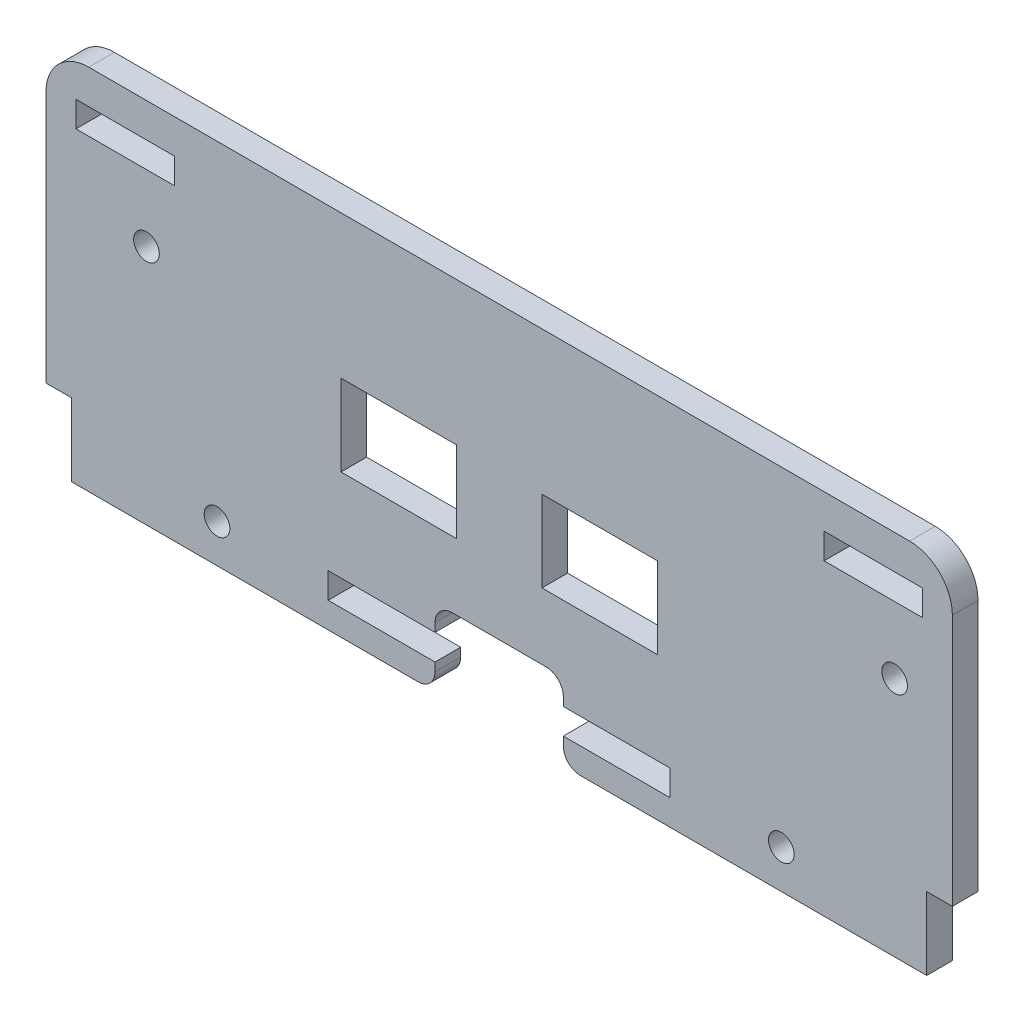
from build123d import *

# Parameters (mm, degrees)
ESBO_O1_W                 = 100
ESBO_O1_H                 = 43
RESSALTO_EXTRUS_O1_DEPTH  = 1.5
ESBO_O2_R                 = 1.5
CORTE_EXTRUS_O1_DEPTH     = 4
SKETCH7_W                 = 13.5
SKETCH7_H                 = 9.5
CUT_EXTRUDE6_DEPTH        = 2.5
CUT_EXTRUDE6_DEPTH_BACK   = 2.5
SKETCH8_W                 = 3
SKETCH8_H                 = 34.5
BOSS_EXTRUDE1_DEPTH       = 1.5
FILLET3_R                 = 2
FILLET4_R                 = 5
SKETCH9_R                 = 1.5
SKETCH9_W                 = 11.5
SKETCH9_H                 = 3
CORTE_GY_53LDK_DEPTH      = 2.5
CORTE_GY_53LDK_DEPTH_BACK = 2.5


with BuildPart() as part:
    # Esboço1 → Ressalto-extrusão1 (new body, symmetric)
    with BuildSketch(Plane.XY):
        Rectangle(ESBO_O1_W, ESBO_O1_H)
    extrude(amount=RESSALTO_EXTRUS_O1_DEPTH, both=True)

    # Esboço2 → Corte-extrusão1 (cut, through all)
    with BuildSketch(Plane.XY.offset(1.5)):
        with Locations((-33, -17)):
            Circle(ESBO_O2_R)
        with Locations((33, -17)):
            Circle(ESBO_O2_R)
        Polygon((-20, -15.5), (-7.5, -15.5), (-7.5, -12.5), (7.5, -12.5), (7.5, -15.5), (20, -15.5), (20, -18.5), (7.5, -18.5), (7.5, -21.5), (-7.5, -21.5), (-7.5, -18.5), (-20, -18.5), align=None)
    extrude(amount=-CORTE_EXTRUS_O1_DEPTH, mode=Mode.SUBTRACT)

    # Sketch7 → Cut-Extrude6 (cut, two sides)
    with BuildSketch(Plane.XY) as cut_extrude6_sk:
        with Locations((-11.75, 0)):
            Rectangle(SKETCH7_W, SKETCH7_H)
        with Locations((11.75, 0)):
            Rectangle(SKETCH7_W, SKETCH7_H)
    extrude(amount=CUT_EXTRUDE6_DEPTH, mode=Mode.SUBTRACT)
    extrude(cut_extrude6_sk.sketch, amount=-CUT_EXTRUDE6_DEPTH_BACK, mode=Mode.SUBTRACT)

    # Sketch8 → Boss-Extrude1 (add, symmetric)
    with BuildSketch(Plane.XY):
        with Locations((-51.5, 4.25)):
            Rectangle(SKETCH8_W, SKETCH8_H)
        with Locations((51.5, 4.25)):
            Rectangle(SKETCH8_W, SKETCH8_H)
    extrude(amount=BOSS_EXTRUDE1_DEPTH, both=True)

    # Fillet3
    fillet3_edges = [part.edges().sort_by_distance(p)[0] for p in [
        (-7.5, -21.5, 0),
        (-7.5, -12.5, 0),
        (7.5, -12.5, 0),
        (7.5, -21.5, 0),
    ]]
    fillet(fillet3_edges, radius=FILLET3_R)

    # Fillet4
    fillet4_edges = [part.edges().sort_by_distance(p)[0] for p in [
        (53, 21.5, 0),
        (-53, 21.5, 0),
    ]]
    fillet(fillet4_edges, radius=FILLET4_R)

    # Sketch9 → Corte Gy-53LDK (cut, two sides)
    with BuildSketch(Plane.XY) as corte_gy_53ldk_sk:
        with Locations((-41.25, 6.7)):
            Circle(SKETCH9_R)
        with Locations((46.25, 6.7)):
            Circle(SKETCH9_R)
        with Locations((-43.75, 16)):
            Rectangle(SKETCH9_W, SKETCH9_H)
        with Locations((43.75, 16)):
            Rectangle(SKETCH9_W, SKETCH9_H)
    extrude(amount=CORTE_GY_53LDK_DEPTH, mode=Mode.SUBTRACT)
    extrude(corte_gy_53ldk_sk.sketch, amount=-CORTE_GY_53LDK_DEPTH_BACK, mode=Mode.SUBTRACT)


solid = part.part
